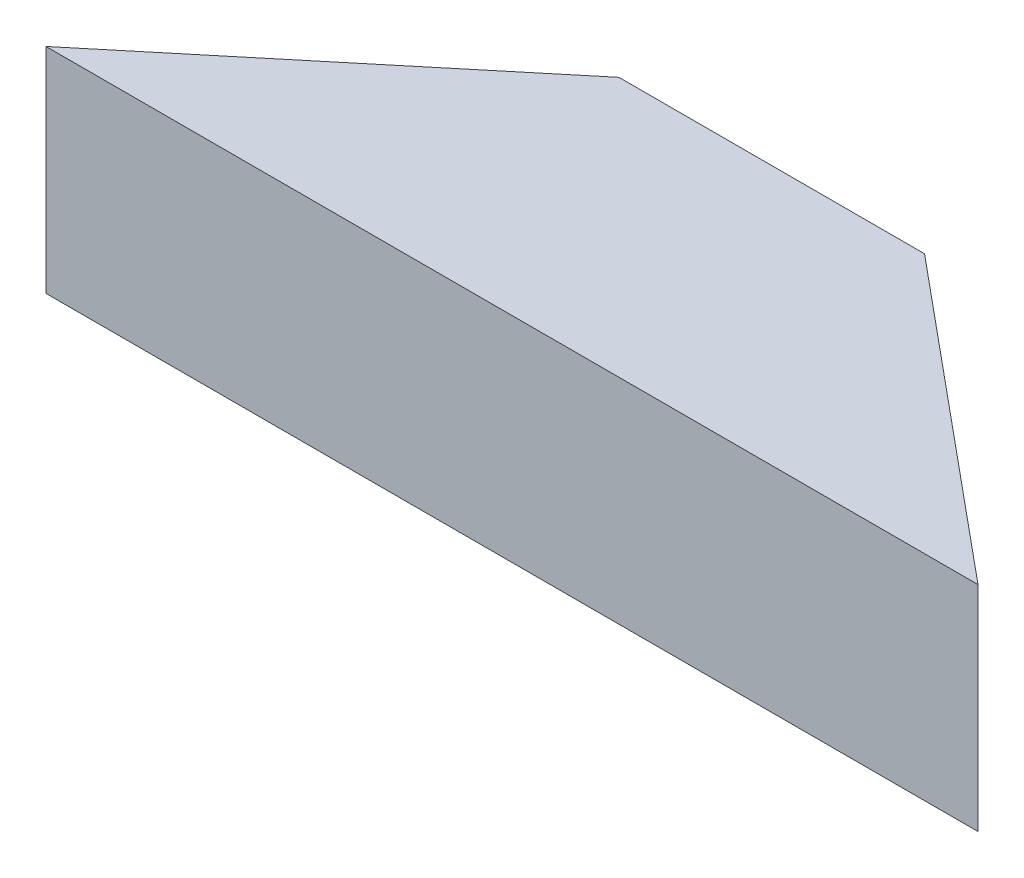
from build123d import *

# Parameters (mm, degrees)
BOSS_EXTRU_1_DEPTH = 2.8


with BuildPart() as part:
    # Esquisse1 → Boss.-Extru.1 (new body)
    with BuildSketch(Plane(origin=(0, 0, 0), x_dir=(1, 0, 0), z_dir=(0, 1, 0))):
        Polygon((0, 0), (12.2, 0), (8.1, 3.4), (4.1, 3.4), align=None)
    extrude(amount=BOSS_EXTRU_1_DEPTH)


solid = part.part
